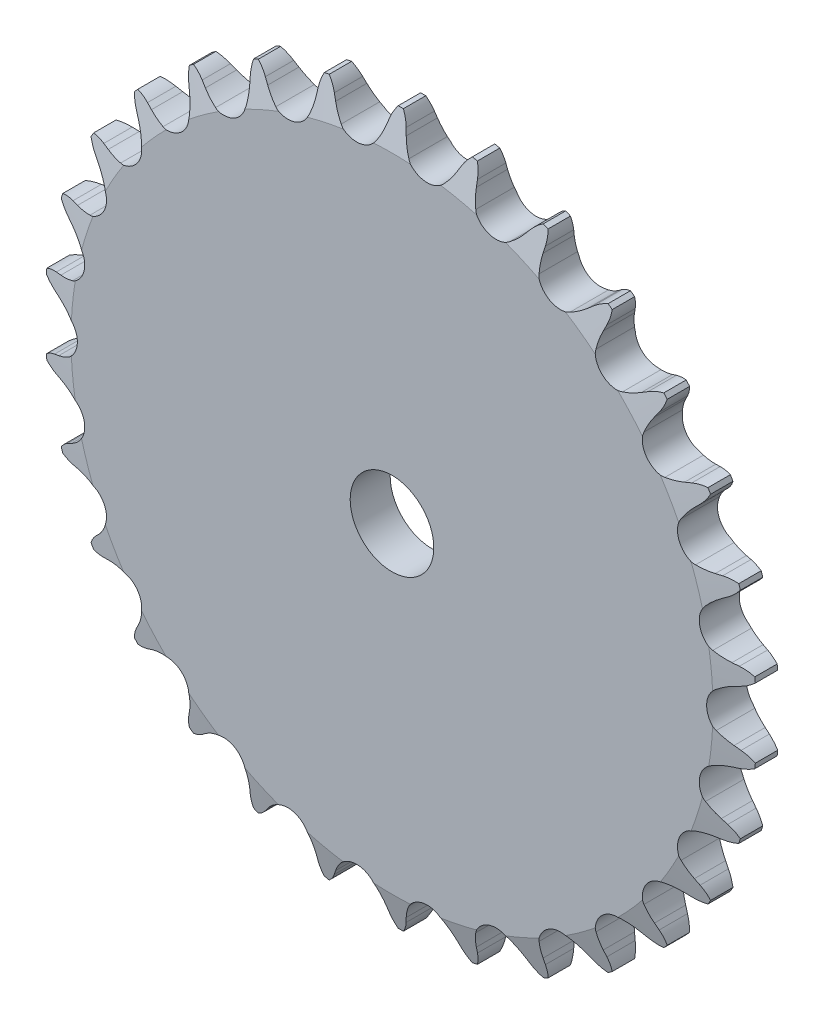
from build123d import *

# Parameters (mm, degrees)
CUT_EXTRUDE1_DEPTH      = 91.901167258
CIRPATTERN1_COUNT       = 30
CUT_EXTRUDE2_DEPTH      = 91.686000123
CUT_EXTRUDE2_DEPTH_BACK = 91.686000123
SKETCH3_OUTSIDE_W       = 166.116
SKETCH3_OUTSIDE_H       = 166.726
SKETCH3_OUTSIDE_R       = 64.262
SKETCH3_OUTSIDE_R_2     = 7.540625


with BuildPart() as part:
    # Sketch1 → Revolve1 (revolve)
    with BuildSketch(Plane(origin=(0, 0, 0), x_dir=(0, 0, -1), z_dir=(1, 0, 0)), mode=Mode.PRIVATE) as revolve1_sk:
        Polygon((3.6068, 0), (-3.6068, 0), (-3.6068, 57.876214284), (-2.0193, 64.226214284), (2.0193, 64.226214284), (3.6068, 57.876214284), align=None)
    revolve(revolve1_sk.sketch.rotate(Axis((0, 0, -3.6068), (0, 0, 1)), 90), axis=Axis((0, 0, -3.6068), (0, 0, 1)))

    # Sketch0 → Cut-Extrude1 (cut, symmetric)
    with BuildSketch(Plane.XY):
        with BuildLine():
            Line((11.445503303, -61.025858703), (10.955217901, -60.058058326))
            ThreePointArc((10.955217901, -60.058058326), (10.206782717, -58.807514261), (9.290270063, -57.674368093))
            ThreePointArc((9.290270063, -57.674368093), (5.929762965, -56.417925974), (2.903920015, -58.345600531))
            ThreePointArc((2.903920015, -58.345600531), (2.243029697, -59.644538432), (1.770952349, -61.023363533))
            Line((1.770952349, -61.023363533), (1.492597872, -62.071951217))
            ThreePointArc((1.492597872, -62.071951217), (-1.013637173, -65.681631643), (-5.249970182, -66.849745296))
            ThreePointArc((-5.249970182, -66.849745296), (7.009216594, -66.688241211), (19.034089313, -64.297387793))
            ThreePointArc((19.034089313, -64.297387793), (14.647465859, -64.035583385), (11.445503303, -61.025858703))
        make_face()
    cut_extrude1 = extrude(amount=CUT_EXTRUDE1_DEPTH, both=True, mode=Mode.SUBTRACT)

    # CirPattern1: Cut-Extrude1 ×30 about axis
    cirpattern1_axis = Axis((0, 0, 0), (0, 0, 1))
    for i in range(1, CIRPATTERN1_COUNT):
        add(cut_extrude1.rotate(cirpattern1_axis, i * 360 / CIRPATTERN1_COUNT), mode=Mode.SUBTRACT)

    # Sketch3 outside → Cut-Extrude2 (cut, two sides: drawn at the far end of the back side and taken through both)
    # profile 1 of 2: a face of its own
    with BuildSketch(Plane.XY.offset(-CUT_EXTRUDE2_DEPTH_BACK)):
        Rectangle(SKETCH3_OUTSIDE_W, SKETCH3_OUTSIDE_H)
        Circle(SKETCH3_OUTSIDE_R, mode=Mode.SUBTRACT)
    # profile 2 of 2: a face of its own
    with BuildSketch(Plane.XY.offset(-CUT_EXTRUDE2_DEPTH_BACK)):
        with Locations(Location((0, 0, 0), (0, 0, 180))):
            Circle(SKETCH3_OUTSIDE_R_2)
    extrude(amount=CUT_EXTRUDE2_DEPTH + CUT_EXTRUDE2_DEPTH_BACK, mode=Mode.SUBTRACT)


solid = part.part
